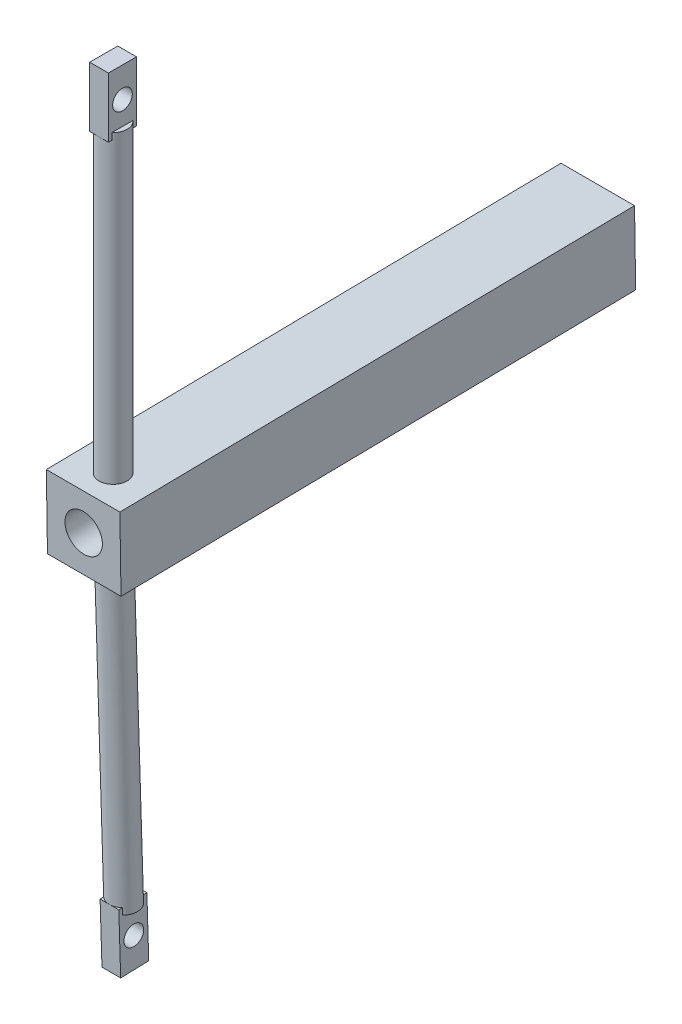
from build123d import *

# Parameters (mm, degrees)
SKETCH1_W           = 78.592769499
SKETCH1_H           = 78.592769498
SKETCH1_R           = 20
BOSS_EXTRUDE4_DEPTH = 550
SWEEP1_PROFILE_R    = 15
SKETCH15_R          = 10.5
BOSS_EXTRUDE5_DEPTH = 10


with BuildPart() as part:
    # Sketch1 → Boss-Extrude4 (new body)
    with BuildSketch(Plane(origin=(4e-09, 27232.877627093, 41716.336726155), x_dir=(1, 0, 0), z_dir=(0, -0.01550283, 0.999879824))):
        with Locations((-23373.04698752, 6409.461295652)):
            Rectangle(SKETCH1_W, SKETCH1_H)
        with Locations((-23373.046987519, 6409.461295652)):
            Circle(SKETCH1_R, mode=Mode.SUBTRACT)
    extrude(amount=-BOSS_EXTRUDE4_DEPTH)

    # Sweep1: sweep along a curve in space
    with BuildLine() as sweep1_path:
        Line((-23373.046987515, 34006.895340042, 41784.248904534), (-23373.046987515, 33681.357429633, 41784.248904534))
    # Sweep1 profile (on start of the path) → Sweep1 (sweep)
    with BuildSketch(Plane(origin=(-23373.046987515, 34006.895340042, 41784.248904534), x_dir=(0, 0, -1), z_dir=(0, -1, 0))):
        Circle(SWEEP1_PROFILE_R)
    sweep1 = sweep(path=sweep1_path.line)

    # Sketch15 → Boss-Extrude5 (add, symmetric)
    with BuildSketch(Plane(origin=(-23373.046987519, 0, 3e-09), x_dir=(0, 0, 1), z_dir=(-1, 0, 0))):
        Polygon((41769.248904556, 34063.932408428), (41799.248904531, 34063.932408428), (41799.248904531, 33999.858271629), (41769.248904531, 33999.858271629), align=None)
        with Locations((41784.248904537, 34031.895340042)):
            Circle(SKETCH15_R, mode=Mode.SUBTRACT)
    boss_extrude5 = extrude(amount=BOSS_EXTRUDE5_DEPTH, both=True)

    # Mirror1: Sweep1, Boss-Extrude5 across plane
    add(sweep1.mirror(Plane(origin=(0, 34281.667133734, 531.526740505), x_dir=(0, -0.01550283, 0.999879824), z_dir=(0, -0.999879824, -0.01550283))))
    add(boss_extrude5.mirror(Plane(origin=(0, 34281.667133734, 531.526740505), x_dir=(0, -0.01550283, 0.999879824), z_dir=(0, -0.999879824, -0.01550283))))


solid = part.part
